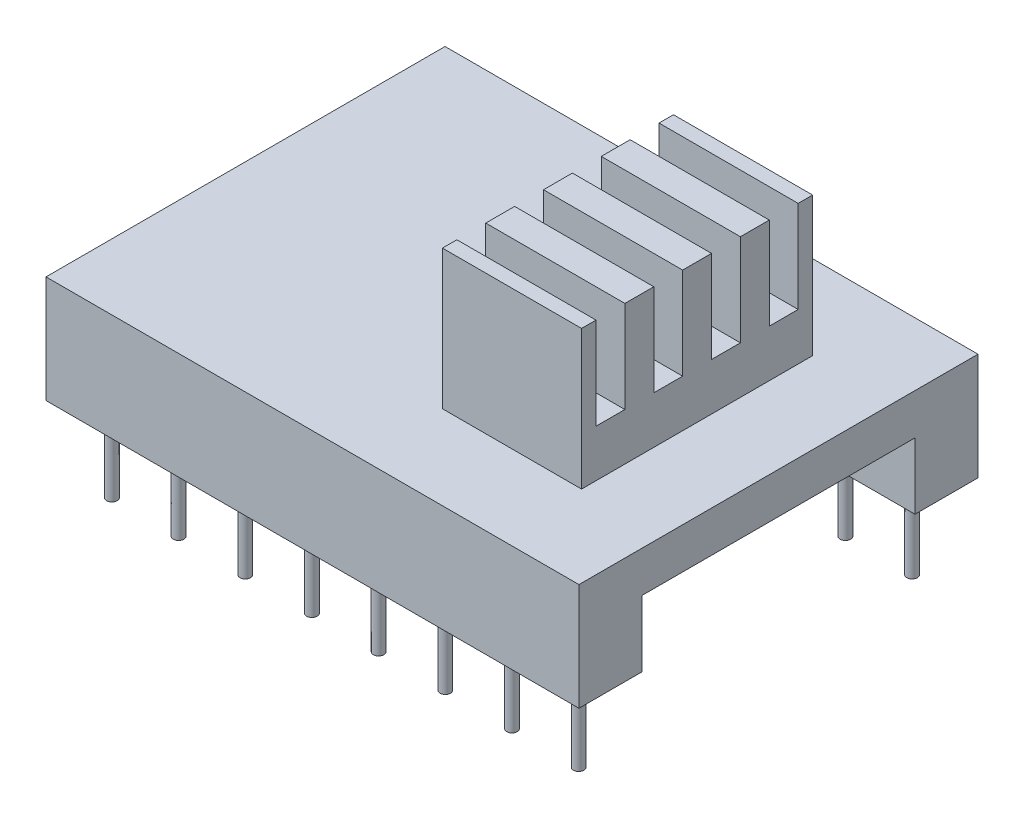
from build123d import *

# Parameters (mm, degrees)
SKETCH1_W               = 20.3
SKETCH1_H               = 15.2
BOSS_EXTRUDE1_DEPTH     = 1.56
SKETCH2_W               = 20.3
SKETCH2_H               = 2.4
BOSS_EXTRUDE2_DEPTH     = 2.52
SKETCH3_R               = 0.2
BOSS_EXTRUDE3_DEPTH     = 3.2
LPATTERN1_COUNT         = 8
LPATTERN1_PITCH         = 2.54
MIRROR1_COPY_1_SKETCH_R = 0.2
MIRROR1_COPY_1_DEPTH    = 3.2
MIRROR1_COPY_2_SKETCH_R = 0.2
MIRROR1_COPY_2_DEPTH    = 3.2
MIRROR1_COPY_3_SKETCH_R = 0.2
MIRROR1_COPY_3_DEPTH    = 3.2
MIRROR1_COPY_4_SKETCH_R = 0.2
MIRROR1_COPY_4_DEPTH    = 3.2
MIRROR1_COPY_5_SKETCH_R = 0.2
MIRROR1_COPY_5_DEPTH    = 3.2
MIRROR1_COPY_6_SKETCH_R = 0.2
MIRROR1_COPY_6_DEPTH    = 3.2
MIRROR1_COPY_7_SKETCH_R = 0.2
MIRROR1_COPY_7_DEPTH    = 3.2
SKETCH4_W               = 5.3
SKETCH4_H               = 8.8
BOSS_EXTRUDE4_DEPTH     = 5.3
SKETCH5_W               = 1.1
SKETCH5_H               = 3.5
CUT_EXTRUDE1_DEPTH      = 5.3


with BuildPart() as part:
    # Sketch1 → Boss-Extrude1 (new body)
    with BuildSketch(Plane(origin=(0, 0, 0), x_dir=(1, 0, 0), z_dir=(0, 1, 0))):
        Rectangle(SKETCH1_W, SKETCH1_H)
    extrude(amount=BOSS_EXTRUDE1_DEPTH)

    # Sketch2 → Boss-Extrude2 (add)
    with BuildSketch(Plane.XZ):
        with Locations((0, 6.4)):
            Rectangle(SKETCH2_W, SKETCH2_H)
        with Locations((0, -6.4)):
            Rectangle(SKETCH2_W, SKETCH2_H)
    extrude(amount=BOSS_EXTRUDE2_DEPTH)

    # Sketch3 → Boss-Extrude3 (add)
    with BuildSketch(Plane.XZ.offset(2.52)):
        with Locations((-8.89, 6.35)):
            Circle(SKETCH3_R)
    boss_extrude3 = extrude(amount=BOSS_EXTRUDE3_DEPTH)

    # LPattern1: Boss-Extrude3 ×8
    with Locations(*[(i * LPATTERN1_PITCH, 0, 0) for i in range(1, LPATTERN1_COUNT)]):
        add(boss_extrude3)

    # Mirror1: Boss-Extrude3 across plane
    add(boss_extrude3.mirror(Plane.XY))

    # Mirror1 copy 1 sketch → Mirror1 copy 1 (add)
    with BuildSketch(Plane(origin=(2.54, -2.52, 0), x_dir=(1, 0, 0), z_dir=(0, -1, 0))):
        with Locations((-8.89, -6.35)):
            Circle(MIRROR1_COPY_1_SKETCH_R)
    extrude(amount=MIRROR1_COPY_1_DEPTH)

    # Mirror1 copy 2 sketch → Mirror1 copy 2 (add)
    with BuildSketch(Plane(origin=(5.08, -2.52, 0), x_dir=(1, 0, 0), z_dir=(0, -1, 0))):
        with Locations((-8.89, -6.35)):
            Circle(MIRROR1_COPY_2_SKETCH_R)
    extrude(amount=MIRROR1_COPY_2_DEPTH)

    # Mirror1 copy 3 sketch → Mirror1 copy 3 (add)
    with BuildSketch(Plane(origin=(7.62, -2.52, 0), x_dir=(1, 0, 0), z_dir=(0, -1, 0))):
        with Locations((-8.89, -6.35)):
            Circle(MIRROR1_COPY_3_SKETCH_R)
    extrude(amount=MIRROR1_COPY_3_DEPTH)

    # Mirror1 copy 4 sketch → Mirror1 copy 4 (add)
    with BuildSketch(Plane(origin=(10.16, -2.52, 0), x_dir=(1, 0, 0), z_dir=(0, -1, 0))):
        with Locations((-8.89, -6.35)):
            Circle(MIRROR1_COPY_4_SKETCH_R)
    extrude(amount=MIRROR1_COPY_4_DEPTH)

    # Mirror1 copy 5 sketch → Mirror1 copy 5 (add)
    with BuildSketch(Plane(origin=(12.7, -2.52, 0), x_dir=(1, 0, 0), z_dir=(0, -1, 0))):
        with Locations((-8.89, -6.35)):
            Circle(MIRROR1_COPY_5_SKETCH_R)
    extrude(amount=MIRROR1_COPY_5_DEPTH)

    # Mirror1 copy 6 sketch → Mirror1 copy 6 (add)
    with BuildSketch(Plane(origin=(15.24, -2.52, 0), x_dir=(1, 0, 0), z_dir=(0, -1, 0))):
        with Locations((-8.89, -6.35)):
            Circle(MIRROR1_COPY_6_SKETCH_R)
    extrude(amount=MIRROR1_COPY_6_DEPTH)

    # Mirror1 copy 7 sketch → Mirror1 copy 7 (add)
    with BuildSketch(Plane(origin=(17.78, -2.52, 0), x_dir=(1, 0, 0), z_dir=(0, -1, 0))):
        with Locations((-8.89, -6.35)):
            Circle(MIRROR1_COPY_7_SKETCH_R)
    extrude(amount=MIRROR1_COPY_7_DEPTH)

    # Sketch4 → Boss-Extrude4 (add)
    with BuildSketch(Plane(origin=(0, 1.56, 0), x_dir=(1, 0, 0), z_dir=(0, 1, 0))):
        with Locations((4.4, 0)):
            Rectangle(SKETCH4_W, SKETCH4_H)
    extrude(amount=BOSS_EXTRUDE4_DEPTH)

    # Sketch5 → Cut-Extrude1 (cut)
    with BuildSketch(Plane(origin=(7.05, 0, 0), x_dir=(0, 0, -1), z_dir=(1, 0, 0))):
        with Locations((-3.3, 5.11)):
            Rectangle(SKETCH5_W, SKETCH5_H)
        with Locations((-1.1, 5.11)):
            Rectangle(SKETCH5_W, SKETCH5_H)
        with Locations((1.1, 5.11)):
            Rectangle(SKETCH5_W, SKETCH5_H)
        with Locations((3.3, 5.11)):
            Rectangle(SKETCH5_W, SKETCH5_H)
    extrude(amount=-CUT_EXTRUDE1_DEPTH, mode=Mode.SUBTRACT)


solid = part.part
